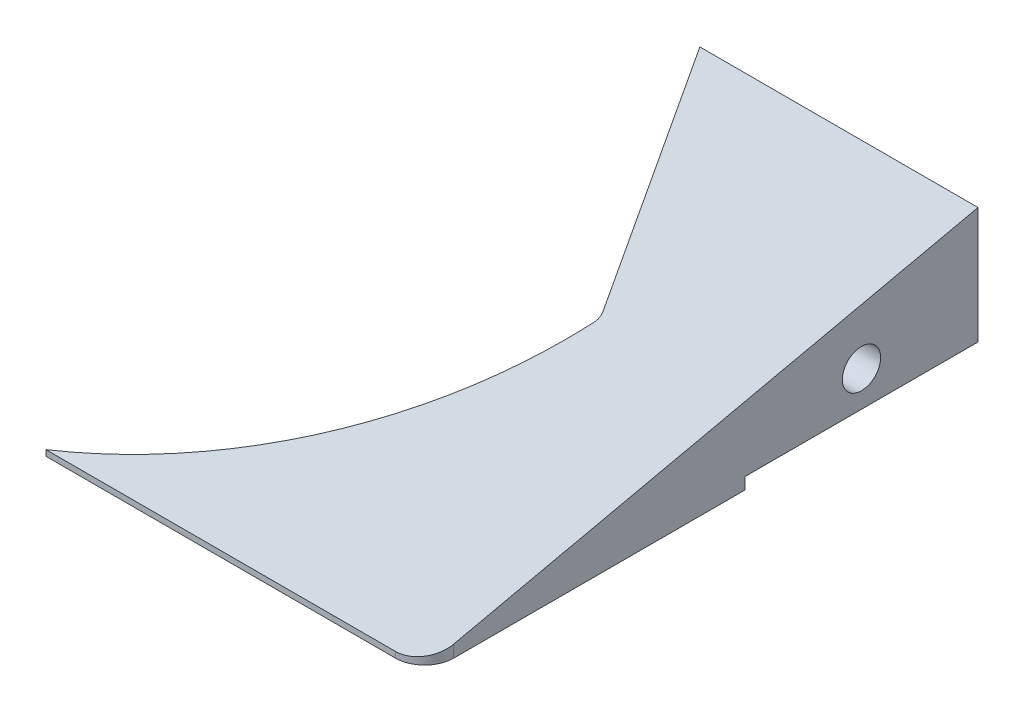
from build123d import *

# Parameters (mm, degrees)
ESBO_O1_W                                      = 130
ESBO_O1_H                                      = 22
RESSALTO_EXTRUS_O1_DEPTH                       = 95
CORTE_EXTRUS_O2_REACH                          = 24
CORTE_EXTRUS_O3_DEPTH                          = 1
CORTE_EXTRUS_O3_DEPTH_BACK                     = 66
BROCA_DE_ROSQUEAR_DE_CANO_PARA_TARRAXA_D_D     = 6.579997
BROCA_DE_ROSQUEAR_DE_CANO_PARA_TARRAXA_D_DEPTH = 10
BROCA_DE_ROSQUEAR_DE_CANO_PARA_TARRAXA_D_TIP   = 1.976830535
BROCA_DE_ROSQUEAR_DE_CANO_PARA_TARRA_2_D       = 6.579997
BROCA_DE_ROSQUEAR_DE_CANO_PARA_TARRA_2_DEPTH   = 10
BROCA_DE_ROSQUEAR_DE_CANO_PARA_TARRA_2_TIP     = 1.976830535
FILETE2_R                                      = 5
ESBO_O16_W                                     = 47.75
ESBO_O16_H                                     = 2
CORTE_EXTRUS_O6_DEPTH                          = 40
FILETE3_R                                      = 3


with BuildPart() as part:
    # Esboço1 → Ressalto-extrusão1 (new body)
    with BuildSketch(Plane.XY):
        Rectangle(ESBO_O1_W, ESBO_O1_H)
    extrude(amount=RESSALTO_EXTRUS_O1_DEPTH)

    # Esboço2 → Corte-extrusão2 (cut, up to next)
    with BuildSketch(Plane(origin=(0, 11, 0), x_dir=(1, 0, 0), z_dir=(0, 1, 0)), mode=Mode.PRIVATE) as corte_extrus_o2_sk1:
        with BuildLine():
            Line((17.25, 0), (-65, 0))
            Line((-65, 0), (-65, -95))
            Line((-65, -95), (0, -95))
            ThreePointArc((0, -95), (26.860074256, -72.440999729), (40.2, -40))
            Line((40.2, -40), (17.25, 0))
        make_face()
    corte_extrus_o2_tool1 = extrude(corte_extrus_o2_sk1.sketch, amount=-CORTE_EXTRUS_O2_REACH, mode=Mode.PRIVATE) & part.part
    add(corte_extrus_o2_tool1.solids().sort_by_distance((-18.119573, 11, 46.581056))[0], mode=Mode.SUBTRACT)

    # Esboço3 → Corte-extrusão3 (cut, two sides)
    with BuildSketch(Plane(origin=(65, 0, 0), x_dir=(0, 0, -1), z_dir=(1, 0, 0))) as corte_extrus_o3_sk:
        Polygon((200.195338438, 55.253706392), (0, 11), (-95, -10), (-295.195338438, -54.253706392), (-383.702751221, 346.136970485), (111.687925655, 455.644383268), align=None)
    extrude(amount=CORTE_EXTRUS_O3_DEPTH, mode=Mode.SUBTRACT)
    extrude(corte_extrus_o3_sk.sketch, amount=-CORTE_EXTRUS_O3_DEPTH_BACK, mode=Mode.SUBTRACT)

    # Broca de rosquear de cano para tarraxa d
    with Locations(Plane(origin=(65, 0, 0), x_dir=(0, 0, -1), z_dir=(1, 0, 0))):
        with Locations((-20, -2.945)):
            Hole(BROCA_DE_ROSQUEAR_DE_CANO_PARA_TARRAXA_D_D / 2, depth=BROCA_DE_ROSQUEAR_DE_CANO_PARA_TARRAXA_D_DEPTH)
            with Locations((0, 0, -(BROCA_DE_ROSQUEAR_DE_CANO_PARA_TARRAXA_D_DEPTH + BROCA_DE_ROSQUEAR_DE_CANO_PARA_TARRAXA_D_TIP / 2))):  # 118° drill point
                Cone(0, BROCA_DE_ROSQUEAR_DE_CANO_PARA_TARRAXA_D_D / 2, BROCA_DE_ROSQUEAR_DE_CANO_PARA_TARRAXA_D_TIP, mode=Mode.SUBTRACT)

    # Broca de rosquear de cano para tarra 2
    with Locations(Plane(origin=(12.977837756, 0, -7.446034412), x_dir=(0.497656085, 0, 0.867374441), z_dir=(-0.867374441, 0, 0.497656085))):
        with Locations((28.584567474, -2.945)):
            Hole(BROCA_DE_ROSQUEAR_DE_CANO_PARA_TARRA_2_D / 2, depth=BROCA_DE_ROSQUEAR_DE_CANO_PARA_TARRA_2_DEPTH)
            with Locations((0, 0, -(BROCA_DE_ROSQUEAR_DE_CANO_PARA_TARRA_2_DEPTH + BROCA_DE_ROSQUEAR_DE_CANO_PARA_TARRA_2_TIP / 2))):  # 118° drill point
                Cone(0, BROCA_DE_ROSQUEAR_DE_CANO_PARA_TARRA_2_D / 2, BROCA_DE_ROSQUEAR_DE_CANO_PARA_TARRA_2_TIP, mode=Mode.SUBTRACT)

    # Filete2
    filete2_edges = [part.edges().sort_by_distance(p)[0] for p in [
        (65, -10.5, 95),
    ]]
    fillet(filete2_edges, radius=FILETE2_R)

    # Esboço16 → Corte-extrusão6 (cut)
    with BuildSketch(Plane(origin=(0, 0, 0), x_dir=(-1, 0, 0), z_dir=(0, 0, -1))):
        with Locations((-41.125, -10)):
            Rectangle(ESBO_O16_W, ESBO_O16_H)
    extrude(amount=-CORTE_EXTRUS_O6_DEPTH, mode=Mode.SUBTRACT)

    # Filete3
    filete3_edges = [part.edges().sort_by_distance(p)[0] for p in [
        (40.2, -3.421052632, 40),
    ]]
    fillet(filete3_edges, radius=FILETE3_R)


solid = part.part
